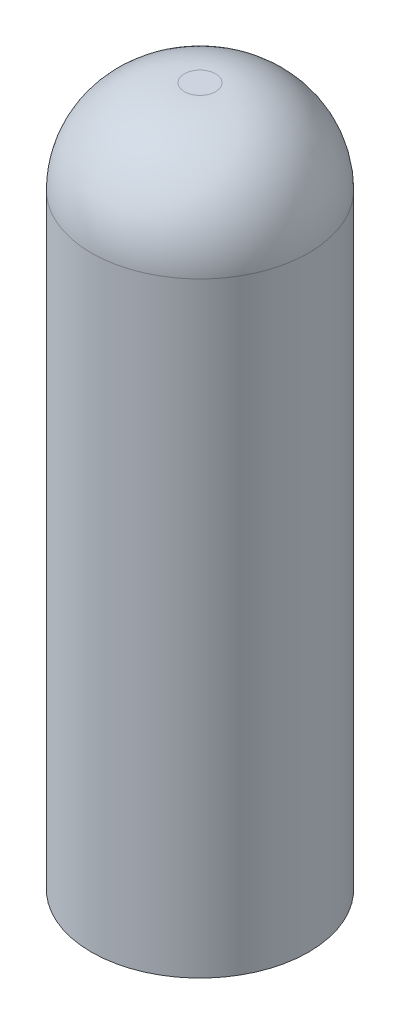
from build123d import *

# Parameters (mm, degrees)
SKETCH1_R           = 7
BOSS_EXTRUDE1_DEPTH = 45
FILLET1_R           = 6
SKETCH2_R           = 2.05
CUT_EXTRUDE1_DEPTH  = 6


with BuildPart() as part:
    # Sketch1 → Boss-Extrude1 (new body)
    with BuildSketch(Plane(origin=(0, 0, 0), x_dir=(1, 0, 0), z_dir=(0, 1, 0))):
        Circle(SKETCH1_R)
    extrude(amount=BOSS_EXTRUDE1_DEPTH)

    # Fillet1
    fillet1_edges = [part.edges().sort_by_distance(p)[0] for p in [
        (-7, 45, 0),
    ]]
    fillet(fillet1_edges, radius=FILLET1_R)

    # Sketch2 → Cut-Extrude1 (cut)
    with BuildSketch(Plane.XZ):
        Circle(SKETCH2_R)
    extrude(amount=-CUT_EXTRUDE1_DEPTH, mode=Mode.SUBTRACT)


solid = part.part
